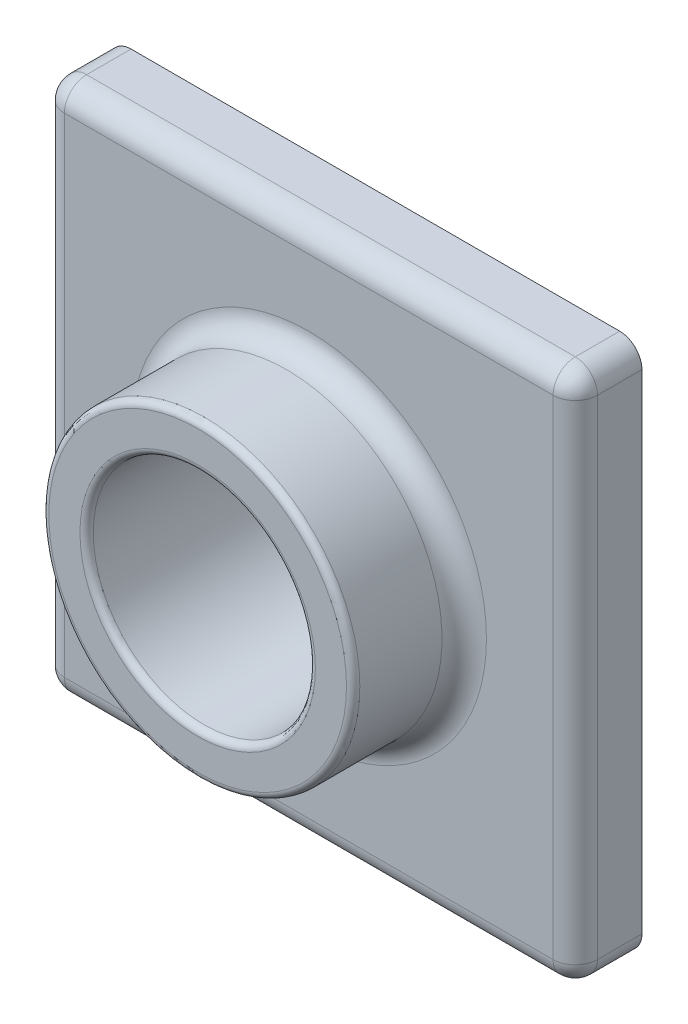
from build123d import *

# Parameters (mm, degrees)
SKETCH2_W           = 120
SKETCH2_H           = 120
BOSS_EXTRUDE1_DEPTH = 15
SKETCH3_R           = 35
BOSS_EXTRUDE2_DEPTH = 25
SKETCH4_R           = 25
CUT_EXTRUDE1_DEPTH  = 175.355957742
FILLET1_R           = 5
FILLET2_R           = 1.5
SHELL1_T            = -2


with BuildPart() as part:
    # Sketch2 → Boss-Extrude1 (new body)
    with BuildSketch(Plane.XY):
        with Locations((60, 60)):
            Rectangle(SKETCH2_W, SKETCH2_H)
    extrude(amount=BOSS_EXTRUDE1_DEPTH)

    # Sketch3 → Boss-Extrude2 (add)
    with BuildSketch(Plane.XY.offset(15)):
        with Locations(Location((60, 60, 0), (0, 0, 180))):
            Circle(SKETCH3_R)
    extrude(amount=BOSS_EXTRUDE2_DEPTH)

    # Sketch4 → Cut-Extrude1 (cut, through all)
    with BuildSketch(Plane.XY.offset(40)):
        with Locations((60, 60)):
            Circle(SKETCH4_R)
    extrude(amount=-CUT_EXTRUDE1_DEPTH, mode=Mode.SUBTRACT)

    # Fillet1
    fillet1_edges = [part.edges().sort_by_distance(p)[0] for p in [
        (120, 60, 15),
        (60, 120, 15),
        (95, 60, 15),
        (0, 60, 15),
        (60, 0, 15),
        (0, 120, 7.5),
        (120, 120, 7.5),
        (120, 0, 7.5),
        (0, 0, 7.5),
    ]]
    fillet(fillet1_edges, radius=FILLET1_R)

    # Fillet2
    fillet2_edges = [part.edges().sort_by_distance(p)[0] for p in [
        (95, 60, 40),
        (35, 60, 40),
    ]]
    fillet(fillet2_edges, radius=FILLET2_R)

    # Shell1
    shell1_openings = [part.faces().sort_by_distance(p)[0] for p in [
        (60, 1.697056275, 0),
    ]]
    offset(amount=SHELL1_T, openings=shell1_openings, kind=Kind.INTERSECTION)


solid = part.part
